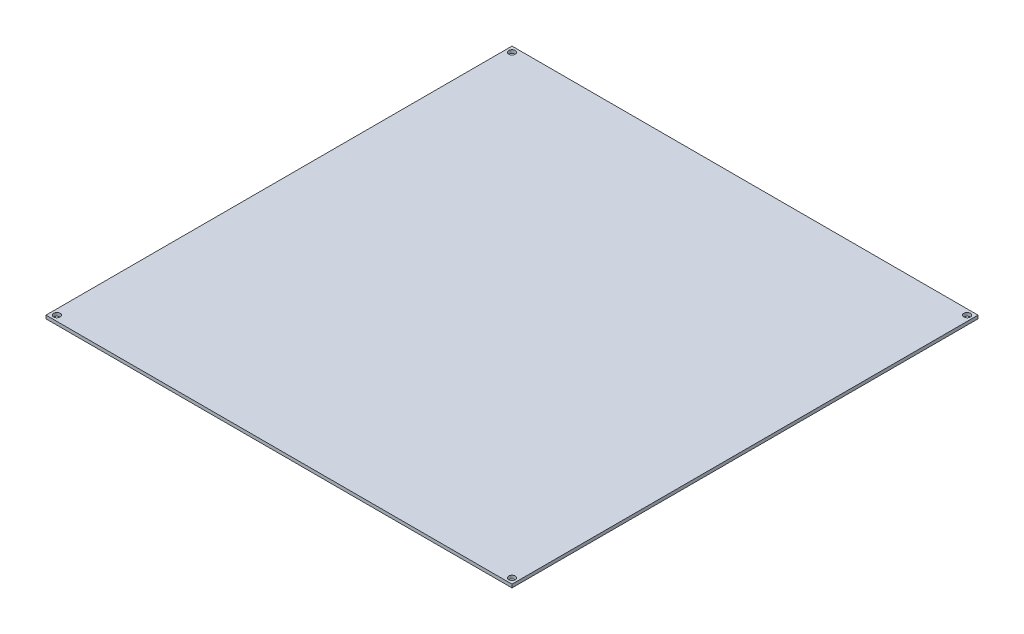
from build123d import *

# Parameters (mm, degrees)
ESQUISSE1_W                   = 214
ESQUISSE1_H                   = 214
BOSS_EXTRU_1_DEPTH            = 1.5
DIAM_TRE_DU_PER_AGE_3_0_3_1_D = 3


with BuildPart() as part:
    # Esquisse1 → Boss.-Extru.1 (new body)
    with BuildSketch(Plane(origin=(0, 0, 0), x_dir=(1, 0, 0), z_dir=(0, 1, 0))):
        with Locations((-2.135097506, -28.367060458)):
            Rectangle(ESQUISSE1_W, ESQUISSE1_H)
    extrude(amount=BOSS_EXTRU_1_DEPTH)

    # Diamètre du perçage Ø3.0 (3)1 (through all)
    with Locations(Plane(origin=(0, 1.5, 0), x_dir=(1, 0, 0), z_dir=(0, 1, 0))):
        with Locations((-106.635097506, -132.867060458), (-106.635097506, 76.132939542), (102.364902494, 76.132939542), (102.364902494, -132.867060458)):
            Hole(DIAM_TRE_DU_PER_AGE_3_0_3_1_D / 2)


solid = part.part
